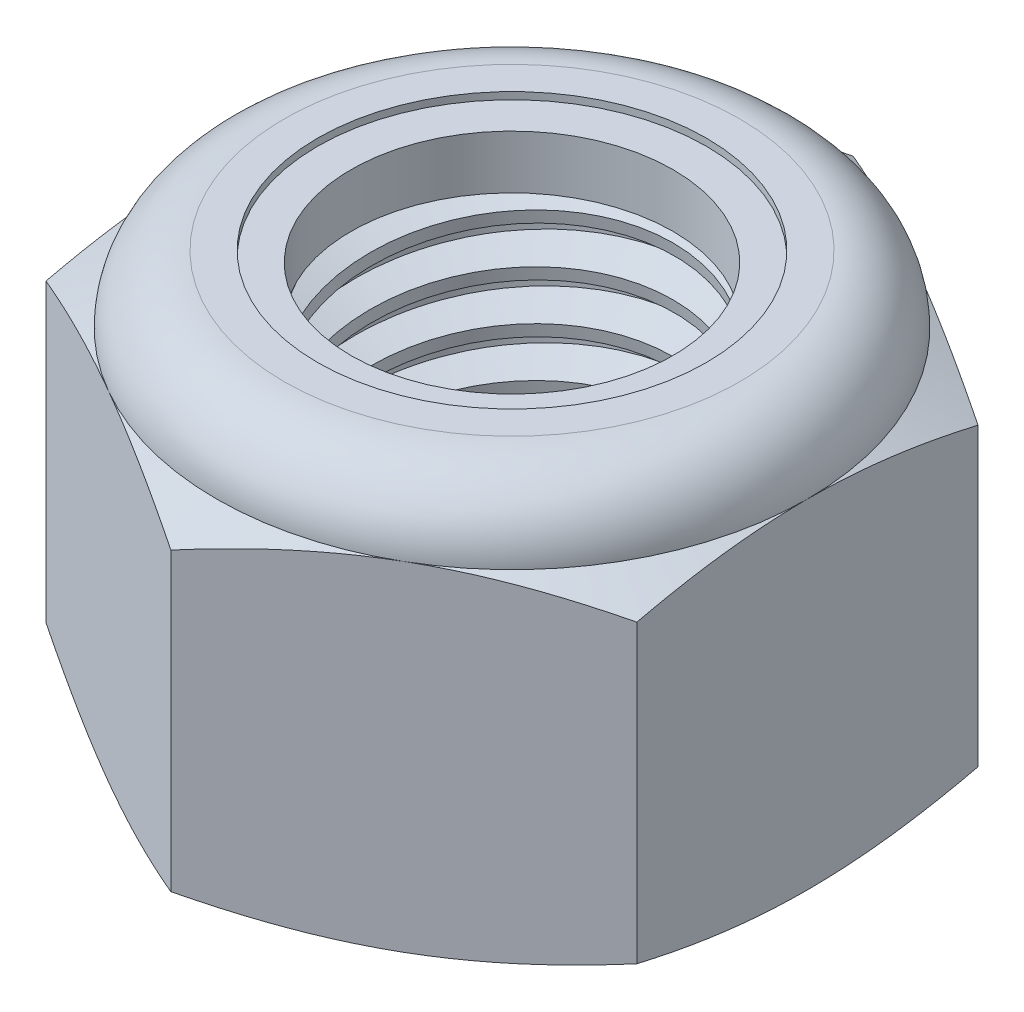
from build123d import *

# Parameters (mm, degrees)
EXTRUDE1_DEPTH      = 8.73125
SKETCH2_W           = 3.96875
SKETCH2_H           = 8.73125
LPATTERN1_COUNT     = 8
LPATTERN1_PITCH     = 1.058333333
LPATTERN1_COL_COUNT = 2
LPATTERN1_COL_PITCH = 1.058333333


with BuildPart() as part:
    # Sketch1 → Extrude1 (new body)
    with BuildSketch(Plane(origin=(0, 0, 0), x_dir=(1, 0, 0), z_dir=(0, 1, 0))):
        Polygon((0, 7.332348419), (-6.35, 3.666174209), (-6.35, -3.666174209), (0, -7.332348419), (6.35, -3.666174209), (6.35, 3.666174209), align=None)
    extrude(amount=EXTRUDE1_DEPTH)

    # Sketch4 → Cut-Revolve2 (revolve, cut)
    with BuildSketch(Plane(origin=(0, 0, 0), x_dir=(0, 0, -1), z_dir=(1, 0, 0)), mode=Mode.PRIVATE) as cut_revolve2_sk:
        Polygon((0, 8.73125), (3.96875, 8.73125), (3.462129843, 8.495009141), (3.462129843, 0.236240859), (3.96875, 0), (0, 0), align=None)
    revolve(cut_revolve2_sk.sketch.rotate(Axis((0, 8.73125, 0), (0, 1, 0)), 54.866222378), axis=Axis((0, 8.73125, 0), (0, 1, 0)), mode=Mode.SUBTRACT)  # turned: the seam where the file's is


with BuildPart() as body_2:
    # Sketch2 → Revolve1 (revolve)
    with BuildSketch(Plane(origin=(0, 0, 0), x_dir=(0, 0, -1), z_dir=(1, 0, 0))):
        with Locations((1.984375, 4.365625)):
            Rectangle(SKETCH2_W, SKETCH2_H)
    revolve(axis=Axis((0, -3.96875, 0), (0, 1, 0)))

    # Sketch3 → Cut-Revolve1 (revolve, cut)
    with BuildSketch(Plane(origin=(0, 0, 0), x_dir=(0, 0, -1), z_dir=(1, 0, 0)), mode=Mode.PRIVATE) as cut_revolve1_sk:
        Polygon((3.986234159, 8.600118809), (4.10862327, 7.682200472), (3.49709816, 7.934319821), (3.462129843, 8.196582203), align=None)
    cut_revolve1 = revolve(cut_revolve1_sk.sketch.rotate(Axis((0, 8.73125, 0.150633003), (0, -0.991227901, -0.13216372)), 180), axis=Axis((0, 8.73125, 0.150633003), (0, -0.991227901, -0.13216372)), mode=Mode.SUBTRACT)  # turned: the seam where the file's is

    # LPattern1: Cut-Revolve1 ×8
    with Locations(*[(0, -i * LPATTERN1_PITCH, 0) for i in range(1, LPATTERN1_COUNT)]):
        add(cut_revolve1, mode=Mode.SUBTRACT)

    # LPattern1 col: Cut-Revolve1 ×2
    with Locations(*[(0, i * LPATTERN1_COL_PITCH, 0) for i in range(1, LPATTERN1_COL_COUNT)]):
        add(cut_revolve1, mode=Mode.SUBTRACT)


with BuildPart() as part_1:
    add(part.part)

    # Combine1: cut body 2
    add(body_2.part, mode=Mode.SUBTRACT)

    # Sketch5 → Cut-Revolve3 (revolve, cut)
    with BuildSketch(Plane(origin=(0, 0, 0), x_dir=(0, 0, -1), z_dir=(1, 0, 0)), mode=Mode.PRIVATE) as cut_revolve3_sk:
        with BuildLine():
            Line((0, 0), (6.35, 0))
            Line((6.35, 0), (7.332348419, 0.458076591))
            Line((7.332348419, 0.458076591), (7.332348419, 6.817965076))
            Line((7.332348419, 6.817965076), (6.35, 7.276041667))
            ThreePointArc((6.35, 7.276041667), (5.923779347, 8.305029347), (4.894791667, 8.73125))
            Line((4.894791667, 8.73125), (4.894791667, 10.00125))
            Line((4.894791667, 10.00125), (8.602348419, 10.00125))
            Line((8.602348419, 10.00125), (8.602348419, -1.27))
            Line((8.602348419, -1.27), (0, -1.27))
            Line((0, -1.27), (0, 0))
        make_face()
    revolve(cut_revolve3_sk.sketch.rotate(Axis((0, 0, 0), (0, 1, 0)), 54.866222378), axis=Axis((0, 0, 0), (0, 1, 0)), mode=Mode.SUBTRACT)  # turned: the seam where the file's is

    # Sketch6 → Cut-Revolve4 (revolve, cut)
    with BuildSketch(Plane(origin=(0, 0, 0), x_dir=(0, 0, -1), z_dir=(1, 0, 0)), mode=Mode.PRIVATE) as cut_revolve4_sk:
        with BuildLine():
            Line((0, 7.276041667), (6.1976, 7.276041667))
            ThreePointArc((6.1976, 7.276041667), (5.816016274, 8.197266274), (4.894791667, 8.57885))
            Line((4.894791667, 8.57885), (4.178460755, 8.57885))
            Line((4.178460755, 8.57885), (4.178460755, 10.00125))
            Line((4.178460755, 10.00125), (0, 10.00125))
            Line((0, 10.00125), (0, 7.276041667))
        make_face()
    revolve(cut_revolve4_sk.sketch.rotate(Axis((0, 10.00125, 0), (0, 1, 0)), 54.866222378), axis=Axis((0, 10.00125, 0), (0, 1, 0)), mode=Mode.SUBTRACT)  # turned: the seam where the file's is


with BuildPart() as body_2_2:
    # Sketch7 → Revolve2 (revolve)
    with BuildSketch(Plane(origin=(0, 0, 0), x_dir=(0, 0, -1), z_dir=(1, 0, 0)), mode=Mode.PRIVATE) as revolve2_sk:
        with BuildLine():
            Line((3.462129843, 7.352241667), (6.119030844, 7.352241667))
            ThreePointArc((6.119030844, 7.352241667), (5.734762038, 8.169919611), (4.894791667, 8.50265))
            Line((4.894791667, 8.50265), (3.462129843, 8.50265))
            Line((3.462129843, 8.50265), (3.462129843, 7.352241667))
        make_face()
    revolve(revolve2_sk.sketch.rotate(Axis((0, 7.352241667, 0), (0, 1, 0)), 54.866222378), axis=Axis((0, 7.352241667, 0), (0, 1, 0)))  # turned: the seam where the file's is


solid = Compound([part_1.part, body_2_2.part])
